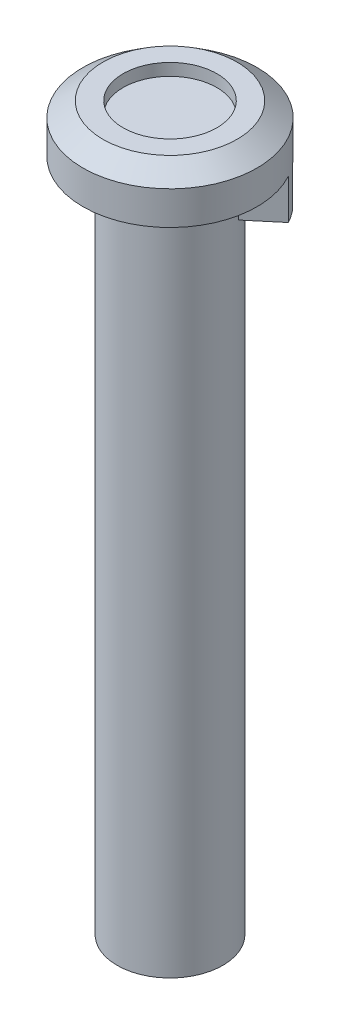
from build123d import *

# Parameters (mm, degrees)
SKETCH1_W           = 3.95
SKETCH1_H           = 50.3
BOSS_EXTRUDE1_DEPTH = 1.25
SKETCH4_W           = 6.5
SKETCH4_H           = 3
BOSS_EXTRUDE2_DEPTH = 1.25
SKETCH5_OUTSIDE_W   = 26.39
SKETCH5_OUTSIDE_H   = 26.39
SKETCH5_OUTSIDE_R   = 6.5
CUT_EXTRUDE1_DEPTH  = 54.9


with BuildPart() as part:
    # Sketch1 → Revolve1 (revolve)
    with BuildSketch(Plane.XY):
        with Locations((1.975, -25.15)):
            Rectangle(SKETCH1_W, SKETCH1_H)
    revolve(axis=Axis((0, 55, 0), (0, -1, 0)))

    # Sketch2 → Revolve2 (revolve)
    with BuildSketch(Plane.XY):
        Polygon((0, 0), (6.5, 0), (6.5, 2.5), (5, 3.6), (3.5, 3.6), (3.5, 2.7), (0, 2.7), align=None)
    revolve(axis=Axis((0, 55, 0), (0, -1, 0)))

    # Sketch3 → Boss-Extrude1 (add)
    with BuildSketch(Plane(origin=(0, 0, 0), x_dir=(0.766044443, 0, -0.64278761), z_dir=(0.64278761, 0, 0.766044443))):
        Polygon((0, 0), (6.5, 0), (0, -6.5), align=None)
    extrude(amount=-BOSS_EXTRUDE1_DEPTH)

    # Sketch4 → Boss-Extrude2 (add)
    with BuildSketch(Plane(origin=(0, 0, 0), x_dir=(0.766044443, 0, -0.64278761), z_dir=(0.64278761, 0, 0.766044443))):
        with Locations((3.25, -1.5)):
            Rectangle(SKETCH4_W, SKETCH4_H)
    extrude(amount=BOSS_EXTRUDE2_DEPTH)

    # Sketch5 outside → Cut-Extrude1 (cut, through all)
    with BuildSketch(Plane(origin=(0, 3.6, 0), x_dir=(1, 0, 0), z_dir=(0, 1, 0))):
        Rectangle(SKETCH5_OUTSIDE_W, SKETCH5_OUTSIDE_H)
        Circle(SKETCH5_OUTSIDE_R, mode=Mode.SUBTRACT)
    extrude(amount=-CUT_EXTRUDE1_DEPTH, mode=Mode.SUBTRACT)


solid = part.part
